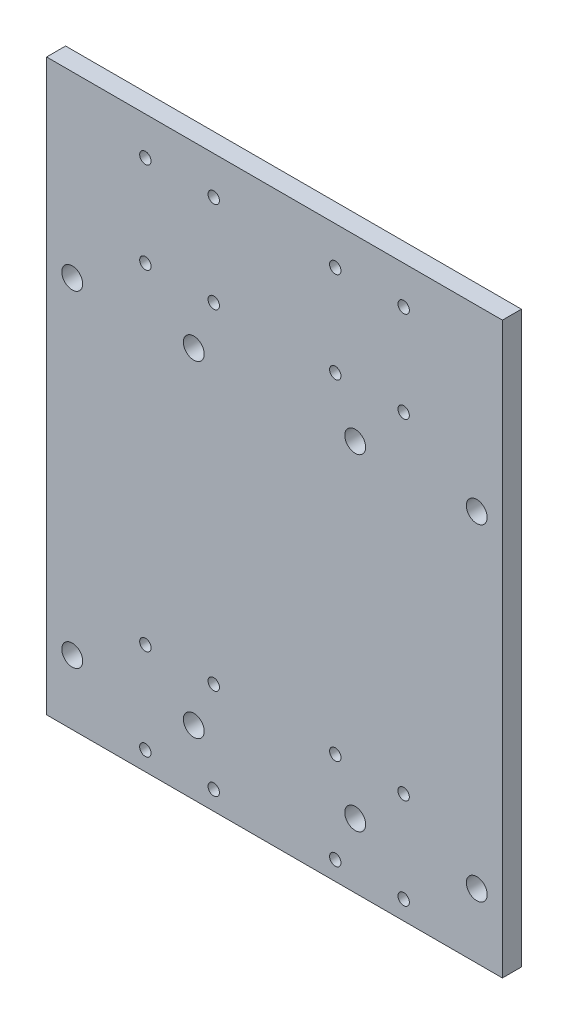
from build123d import *

# Parameters (mm, degrees)
SKETCH1_W               = 120
SKETCH1_H               = 150
BOSS_EXTRUDE1_DEPTH     = 5
SKETCH2_R               = 2.75
ROD_HOLDER_MH_DEPTH     = 6
SKETCH3_R               = 1.5
LINEAR_BEARING_MH_DEPTH = 6


with BuildPart() as part:
    # Sketch1 → Boss-Extrude1 (new body)
    with BuildSketch(Plane.XY):
        Rectangle(SKETCH1_W, SKETCH1_H)
    extrude(amount=BOSS_EXTRUDE1_DEPTH)

    # Sketch2 → rod_holder_mh (cut, through all)
    with BuildSketch(Plane.XY.offset(5)):
        with Locations((-53.25, 28)):
            Circle(SKETCH2_R)
        with Locations((-21.25, 28)):
            Circle(SKETCH2_R)
        with Locations((-53.25, -58)):
            Circle(SKETCH2_R)
        with Locations((-21.25, -58)):
            Circle(SKETCH2_R)
        with Locations((53.25, -58)):
            Circle(SKETCH2_R)
        with Locations((21.25, -58)):
            Circle(SKETCH2_R)
        with Locations((53.25, 28)):
            Circle(SKETCH2_R)
        with Locations((21.25, 28)):
            Circle(SKETCH2_R)
    extrude(amount=-ROD_HOLDER_MH_DEPTH, mode=Mode.SUBTRACT)

    # Sketch3 → linear_bearing_mh (cut, through all)
    with BuildSketch(Plane(origin=(0, 0, 0), x_dir=(-1, 0, 0), z_dir=(0, 0, -1))):
        with Locations((34, -70)):
            Circle(SKETCH3_R)
        with Locations((34, -46)):
            Circle(SKETCH3_R)
        with Locations((16, -70)):
            Circle(SKETCH3_R)
        with Locations((16, -46)):
            Circle(SKETCH3_R)
        with Locations((-16, -70)):
            Circle(SKETCH3_R)
        with Locations((-16, -46)):
            Circle(SKETCH3_R)
        with Locations((-34, -70)):
            Circle(SKETCH3_R)
        with Locations((-34, -46)):
            Circle(SKETCH3_R)
        with Locations((-16, 41)):
            Circle(SKETCH3_R)
        with Locations((-16, 65)):
            Circle(SKETCH3_R)
        with Locations((-34, 41)):
            Circle(SKETCH3_R)
        with Locations((-34, 65)):
            Circle(SKETCH3_R)
        with Locations((34, 41)):
            Circle(SKETCH3_R)
        with Locations((34, 65)):
            Circle(SKETCH3_R)
        with Locations((16, 41)):
            Circle(SKETCH3_R)
        with Locations((16, 65)):
            Circle(SKETCH3_R)
    extrude(amount=-LINEAR_BEARING_MH_DEPTH, mode=Mode.SUBTRACT)


solid = part.part
